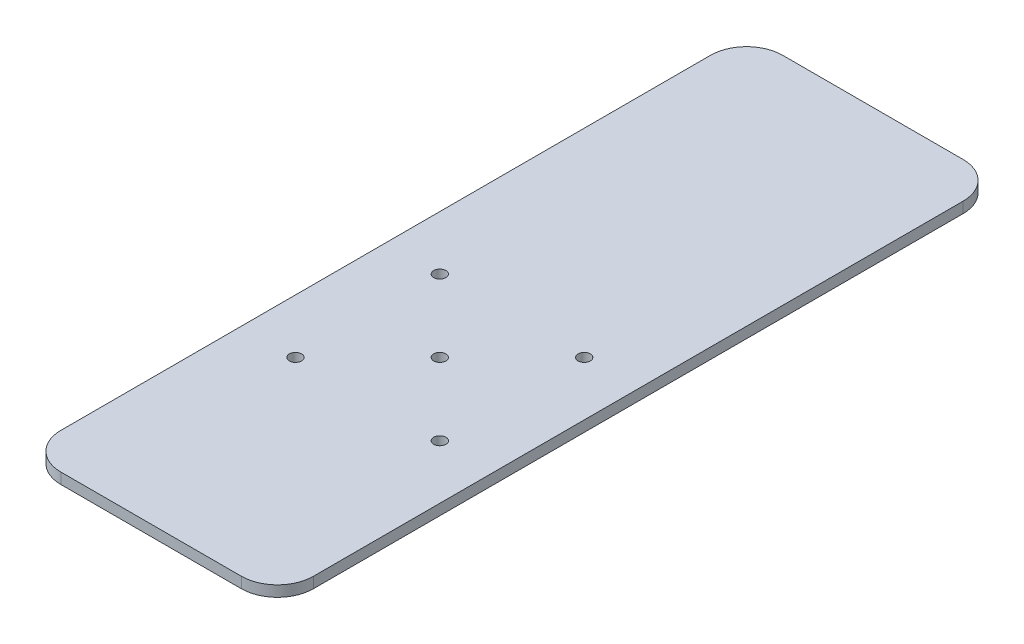
from build123d import *

# Parameters (mm, degrees)
SALIENTE_EXTRUIR1_DEPTH      = 3
TALADRO_DE_MARGEN_PARA_M31_D = 3.4


with BuildPart() as part:
    # Croquis1 → Saliente-Extruir1 (new body)
    with BuildSketch(Plane(origin=(0, 0, 0), x_dir=(1, 0, 0), z_dir=(0, 1, 0))):
        with BuildLine():
            Line((-25, -100), (25, -100))
            ThreePointArc((25, -100), (32.071067812, -97.071067812), (35, -90))
            Line((35, -90), (35, 90))
            ThreePointArc((35, 90), (32.071067812, 97.071067812), (25, 100))
            Line((25, 100), (-25, 100))
            ThreePointArc((-25, 100), (-32.071067812, 97.071067812), (-35, 90))
            Line((-35, 90), (-35, -90))
            ThreePointArc((-35, -90), (-32.071067812, -97.071067812), (-25, -100))
        make_face()
    extrude(amount=SALIENTE_EXTRUIR1_DEPTH)

    # Taladro de margen para M31 (through all)
    with Locations(Plane(origin=(0, 3, 0), x_dir=(1, 0, 0), z_dir=(0, 1, 0))):
        with Locations((-20, 0), (-20, -40), (20, -40), (20, 0), (0, -20)):
            Hole(TALADRO_DE_MARGEN_PARA_M31_D / 2)


solid = part.part
